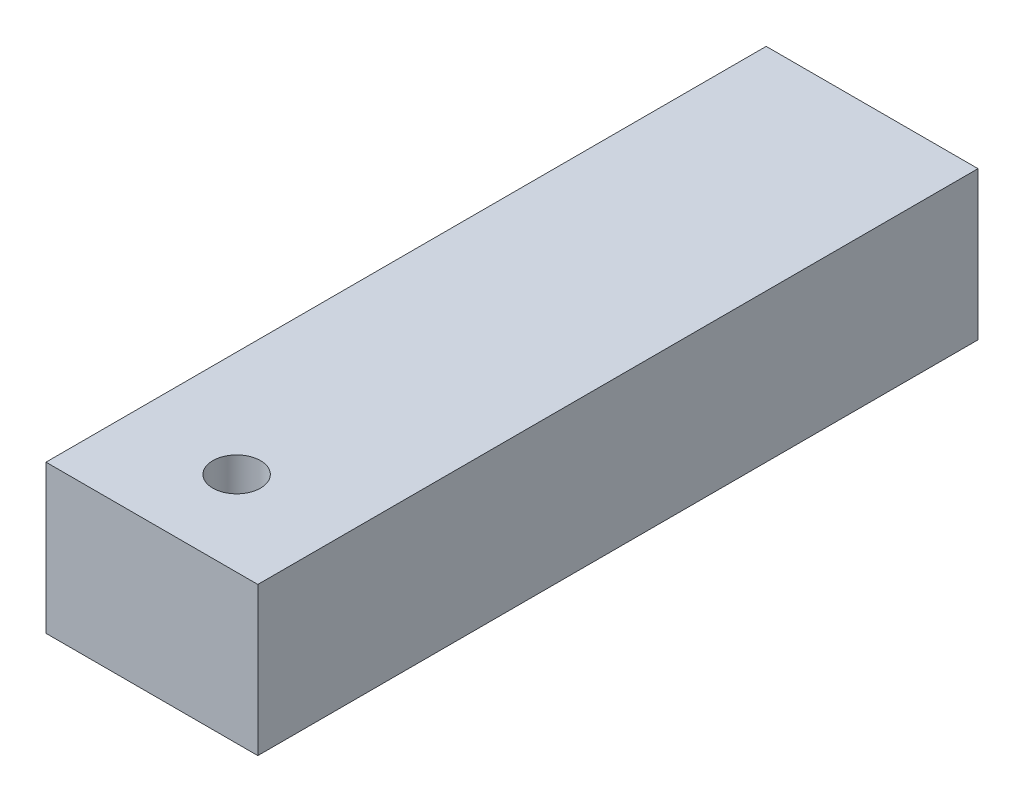
from build123d import *

# Parameters (mm, degrees)
SKIZZE1_W               = 50
SKIZZE1_H               = 35
LINEAR_AUSTRAGEN1_DEPTH = 170
SKIZZE2_R               = 5.634758498
LINEAR_AUSTRAGEN2_DEPTH = 36


with BuildPart() as part:
    # Skizze1 → Linear austragen1 (new body)
    with BuildSketch(Plane.XY):
        Rectangle(SKIZZE1_W, SKIZZE1_H)
    extrude(amount=LINEAR_AUSTRAGEN1_DEPTH)

    # Skizze2 → Linear austragen2 (cut, through all)
    with BuildSketch(Plane(origin=(0, 17.5, 0), x_dir=(1, 0, 0), z_dir=(0, 1, 0))):
        with Locations(Location((0, -150, 0), (0, 0, 270))):  # turned: the seam where the file's is
            Circle(SKIZZE2_R)
    extrude(amount=-LINEAR_AUSTRAGEN2_DEPTH, mode=Mode.SUBTRACT)


solid = part.part
